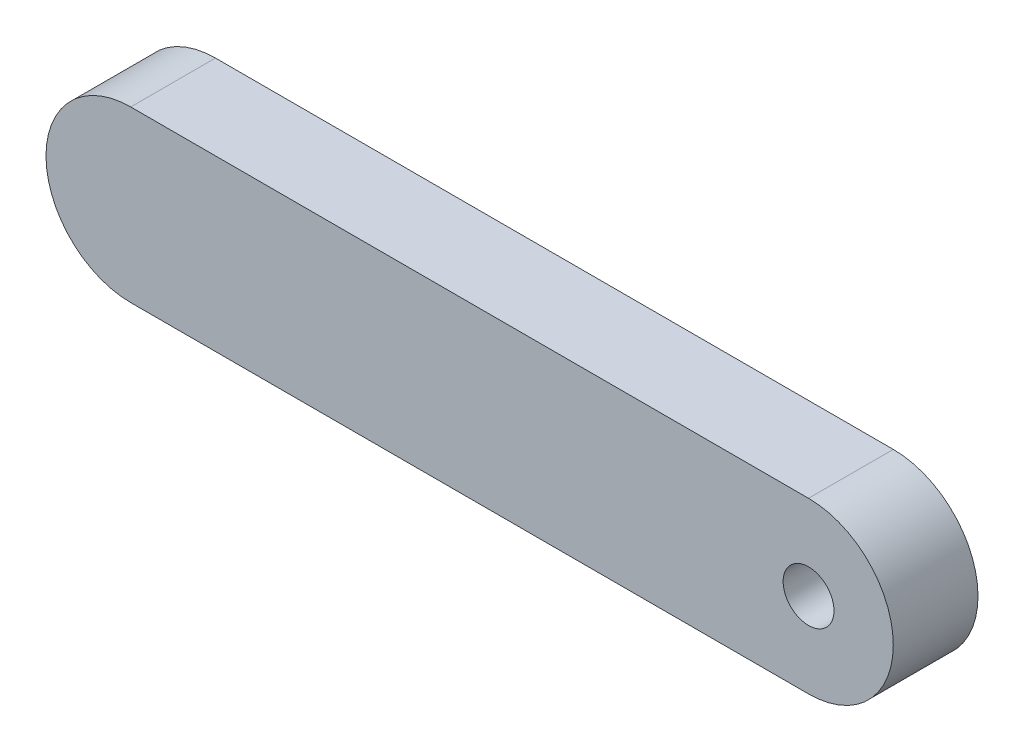
from build123d import *

# Parameters (mm, degrees)
SKETCH1_R           = 1.5
BOSS_EXTRUDE1_DEPTH = 5


with BuildPart() as part:
    # Sketch1 → Boss-Extrude1 (new body)
    with BuildSketch(Plane.XY):
        with BuildLine():
            Line((-20, 5), (20, 5))
            ThreePointArc((20, 5), (25, 0), (20, -5))
            Line((20, -5), (-20, -5))
            ThreePointArc((-20, -5), (-25, 0), (-20, 5))
        make_face()
        with Locations((20, 0)):
            Circle(SKETCH1_R, mode=Mode.SUBTRACT)
    extrude(amount=BOSS_EXTRUDE1_DEPTH)


solid = part.part
